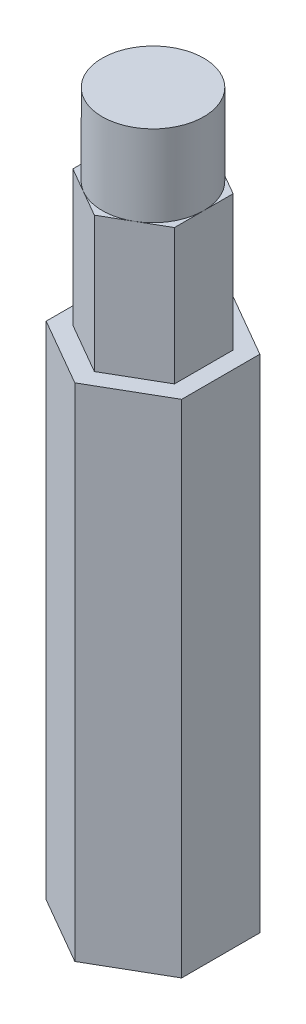
from build123d import *

# Parameters (mm, degrees)
BOSS_EXTRUDE1_DEPTH = 59.69
SKETCH2_R           = 4.7625
BOSS_EXTRUDE2_DEPTH = 67.31
CUT_EXTRUDE1_DEPTH  = 12.7


with BuildPart() as part:
    # Sketch1 → Boss-Extrude1 (new body)
    with BuildSketch(Plane(origin=(0, 0, 0), x_dir=(1, 0, 0), z_dir=(0, 1, 0))):
        Polygon((6.35, -3.666174209), (6.35, 3.666174209), (0, 7.332348419), (-6.35, 3.666174209), (-6.35, -3.666174209), (0, -7.332348419), align=None)
    extrude(amount=BOSS_EXTRUDE1_DEPTH)

    # Sketch2 → Boss-Extrude2 (add)
    with BuildSketch(Plane(origin=(0, 0, 0), x_dir=(1, 0, 0), z_dir=(0, 1, 0))):
        Circle(SKETCH2_R)
    extrude(amount=BOSS_EXTRUDE2_DEPTH)

    # Sketch3 → Cut-Extrude1 (cut)
    with BuildSketch(Plane(origin=(0, 59.69, 0), x_dir=(1, 0, 0), z_dir=(0, 1, 0))):
        Polygon((0, -7.332348419), (6.35, -3.666174209), (6.35, 3.666174209), (0, 7.332348419), (-6.35, 3.666174209), (-6.35, -3.666174209), align=None)
        Polygon((4.7625, -2.749630657), (4.7625, 2.749630657), (0, 5.499261314), (-4.7625, 2.749630657), (-4.7625, -2.749630657), (0, -5.499261314), align=None, mode=Mode.SUBTRACT)
    extrude(amount=-CUT_EXTRUDE1_DEPTH, mode=Mode.SUBTRACT)


solid = part.part
